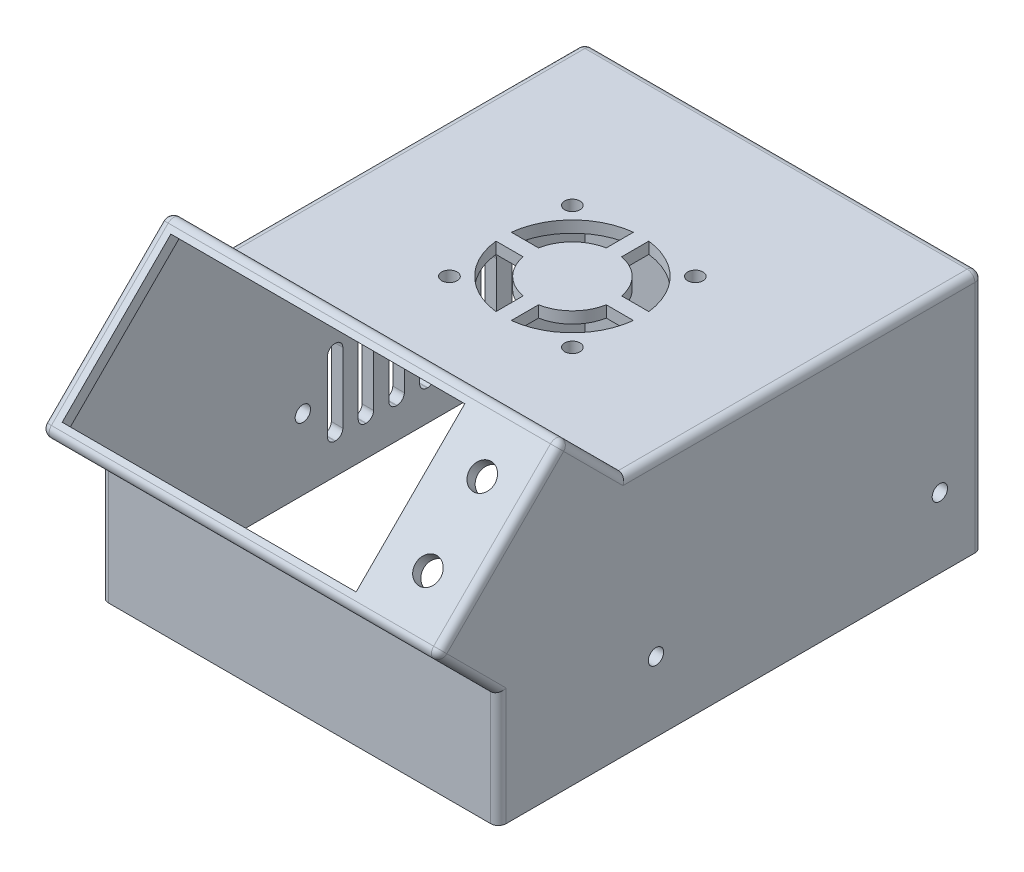
from build123d import *

# Parameters (mm, degrees)
SKETCH1_W           = 103.5
SKETCH1_H           = 126
SKETCH1_W_2         = 97.5
SKETCH1_H_2         = 120
BOSS_EXTRUDE1_DEPTH = 60
SKETCH2_W           = 103.5
SKETCH2_H           = 126
BOSS_EXTRUDE2_DEPTH = 3
CUT_EXTRUDE1_REACH  = 105.5
SKETCH5_W           = 103.5
SKETCH5_H           = 47
SKETCH5_W_2         = 97.5
SKETCH5_H_2         = 41
BOSS_EXTRUDE4_DEPTH = 20
SKETCH6_W           = 97.5
SKETCH6_H           = 41
CUT_EXTRUDE2_DEPTH  = 3
SKETCH7_W           = 103.5
SKETCH7_H           = 47
SKETCH7_R           = 3.25
SKETCH7_W_2         = 76.5
SKETCH7_H_2         = 40
BOSS_EXTRUDE5_DEPTH = 3
CUT_EXTRUDE3_REACH  = 144.263
SKETCH8_R           = 2
SKETCH8_R_2         = 10.5
CUT_EXTRUDE5_REACH  = 65
SKETCH10_R          = 2
SKETCH11_R          = 3
SKETCH11_R_2        = 1
BOSS_EXTRUDE6_DEPTH = 5
CUT_EXTRUDE6_REACH  = 105.5
SKETCH12_R          = 2
SKETCH13_R          = 2
CUT_EXTRUDE7_DEPTH  = 5
FILLET2_R           = 2
FILLET3_R           = 2


with BuildPart() as part:
    # Sketch1 → Boss-Extrude1 (new body)
    with BuildSketch(Plane(origin=(0, 0, 0), x_dir=(1, 0, 0), z_dir=(0, 1, 0))):
        with Locations((48.75, 60)):
            Rectangle(SKETCH1_W, SKETCH1_H)
        with Locations((48.75, 60)):
            Rectangle(SKETCH1_W_2, SKETCH1_H_2, mode=Mode.SUBTRACT)
    extrude(amount=BOSS_EXTRUDE1_DEPTH)

    # Sketch2 → Boss-Extrude2 (add)
    with BuildSketch(Plane(origin=(0, 60, 0), x_dir=(1, 0, 0), z_dir=(0, 1, 0))):
        with Locations((48.75, 60)):
            Rectangle(SKETCH2_W, SKETCH2_H)
    extrude(amount=BOSS_EXTRUDE2_DEPTH)

    # Sketch4 → Cut-Extrude1 (cut, up to next)
    with BuildSketch(Plane(origin=(100.5, 0, 0), x_dir=(0, 0, -1), z_dir=(1, 0, 0)), mode=Mode.PRIVATE) as cut_extrude1_sk1:
        Polygon((-3, 63), (-3, 29.765981284), (30.234018716, 63), align=None)
    cut_extrude1_tool1 = extrude(cut_extrude1_sk1.sketch, amount=-CUT_EXTRUDE1_REACH, mode=Mode.PRIVATE) & part.part
    add(cut_extrude1_tool1.solids().sort_by_distance((100.5, 51.921994, -8.078006))[0], mode=Mode.SUBTRACT)

    # Sketch5 → Boss-Extrude4 (add)
    with BuildSketch(Plane(origin=(0, 16.382990642, 16.382990642), x_dir=(1, 0, 0), z_dir=(0, 0.707106781, 0.707106781))):
        with Locations((48.75, 42.426406871)):
            Rectangle(SKETCH5_W, SKETCH5_H)
        with Locations((48.75, 42.426406871)):
            Rectangle(SKETCH5_W_2, SKETCH5_H_2, mode=Mode.SUBTRACT)
    extrude(amount=BOSS_EXTRUDE4_DEPTH)

    # Sketch6 → Cut-Extrude2 (cut)
    with BuildSketch(Plane(origin=(0, 16.382990642, 16.382990642), x_dir=(1, 0, 0), z_dir=(0, 0.707106781, 0.707106781))):
        with Locations((48.75, 42.426406871)):
            Rectangle(SKETCH6_W, SKETCH6_H)
    extrude(amount=-CUT_EXTRUDE2_DEPTH, mode=Mode.SUBTRACT)

    # Sketch7 → Boss-Extrude5 (add)
    with BuildSketch(Plane(origin=(0, 30.525126266, 30.525126266), x_dir=(1, 0, 0), z_dir=(0, 0.707106781, 0.707106781))):
        with Locations((48.75, 42.426406871)):
            Rectangle(SKETCH7_W, SKETCH7_H)
        with Locations(Location((88.875, 52.426406871, 0), (0, 0, 270))):  # turned: the seam where the file's is
            Circle(SKETCH7_R, mode=Mode.SUBTRACT)
        with Locations(Location((88.875, 32.426406871, 0), (0, 0, 270))):  # turned: the seam where the file's is
            Circle(SKETCH7_R, mode=Mode.SUBTRACT)
        with Locations((39, 42.426406871)):
            Rectangle(SKETCH7_W_2, SKETCH7_H_2, mode=Mode.SUBTRACT)
    extrude(amount=BOSS_EXTRUDE5_DEPTH)

    # Sketch8 → Cut-Extrude3 (cut, up to next)
    with BuildSketch(Plane(origin=(0, 0, -123), x_dir=(-1, 0, 0), z_dir=(0, 0, -1)), mode=Mode.PRIVATE) as cut_extrude3_sk1:
        with Locations((-54.5, 48.5)):
            Circle(SKETCH8_R)
    cut_extrude3_tool1 = extrude(cut_extrude3_sk1.sketch, amount=-CUT_EXTRUDE3_REACH, mode=Mode.PRIVATE) & part.part
    add(cut_extrude3_tool1.solids().sort_by_distance((54.5, 48.5, -123))[0], mode=Mode.SUBTRACT)
    # Sketch8 → Cut-Extrude3 (cut, up to next)
    with BuildSketch(Plane(origin=(0, 0, -123), x_dir=(-1, 0, 0), z_dir=(0, 0, -1)), mode=Mode.PRIVATE) as cut_extrude3_sk2:
        with Locations((-14.5, 48.5)):
            Circle(SKETCH8_R)
    cut_extrude3_tool2 = extrude(cut_extrude3_sk2.sketch, amount=-CUT_EXTRUDE3_REACH, mode=Mode.PRIVATE) & part.part
    add(cut_extrude3_tool2.solids().sort_by_distance((14.5, 48.5, -123))[0], mode=Mode.SUBTRACT)
    # Sketch8 → Cut-Extrude3 (cut, up to next)
    with BuildSketch(Plane(origin=(0, 0, -123), x_dir=(-1, 0, 0), z_dir=(0, 0, -1)), mode=Mode.PRIVATE) as cut_extrude3_sk3:
        with Locations((-74.5, 48.5)):
            Circle(SKETCH8_R_2)
    cut_extrude3_tool3 = extrude(cut_extrude3_sk3.sketch, amount=-CUT_EXTRUDE3_REACH, mode=Mode.PRIVATE) & part.part
    add(cut_extrude3_tool3.solids().sort_by_distance((74.5, 48.5, -123))[0], mode=Mode.SUBTRACT)
    # Sketch8 → Cut-Extrude3 (cut, up to next)
    with BuildSketch(Plane(origin=(0, 0, -123), x_dir=(-1, 0, 0), z_dir=(0, 0, -1)), mode=Mode.PRIVATE) as cut_extrude3_sk4:
        with Locations((-44, 28.7)):
            Circle(SKETCH8_R)
    cut_extrude3_tool4 = extrude(cut_extrude3_sk4.sketch, amount=-CUT_EXTRUDE3_REACH, mode=Mode.PRIVATE) & part.part
    add(cut_extrude3_tool4.solids().sort_by_distance((44, 28.7, -123))[0], mode=Mode.SUBTRACT)
    # Sketch8 → Cut-Extrude3 (cut, up to next)
    with BuildSketch(Plane(origin=(0, 0, -123), x_dir=(-1, 0, 0), z_dir=(0, 0, -1)), mode=Mode.PRIVATE) as cut_extrude3_sk5:
        with BuildLine():
            Line((-46.25, 58), (-22.75, 58))
            ThreePointArc((-22.75, 58), (-21.335786438, 57.414213562), (-20.75, 56))
            Line((-20.75, 56), (-20.75, 41))
            ThreePointArc((-20.75, 41), (-21.335786438, 39.585786438), (-22.75, 39))
            Line((-22.75, 39), (-46.25, 39))
            ThreePointArc((-46.25, 39), (-47.664213562, 39.585786438), (-48.25, 41))
            Line((-48.25, 41), (-48.25, 56))
            ThreePointArc((-48.25, 56), (-47.664213562, 57.414213562), (-46.25, 58))
        make_face()
    cut_extrude3_tool5 = extrude(cut_extrude3_sk5.sketch, amount=-CUT_EXTRUDE3_REACH, mode=Mode.PRIVATE) & part.part
    add(cut_extrude3_tool5.solids().sort_by_distance((34.5, 48.5, -123))[0], mode=Mode.SUBTRACT)

    # Sketch10 → Cut-Extrude5 (cut, up to next)
    with BuildSketch(Plane(origin=(0, 63, 0), x_dir=(1, 0, 0), z_dir=(0, 1, 0)), mode=Mode.PRIVATE) as cut_extrude5_sk1:
        with Locations(Location((32.75, 84, 0), (0, 0, 270))):  # turned: the seam where the file's is
            Circle(SKETCH10_R)
    cut_extrude5_tool1 = extrude(cut_extrude5_sk1.sketch, amount=-CUT_EXTRUDE5_REACH, mode=Mode.PRIVATE) & part.part
    add(cut_extrude5_tool1.solids().sort_by_distance((32.75, 63, -84))[0], mode=Mode.SUBTRACT)
    # Sketch10 → Cut-Extrude5 (cut, up to next)
    with BuildSketch(Plane(origin=(0, 63, 0), x_dir=(1, 0, 0), z_dir=(0, 1, 0)), mode=Mode.PRIVATE) as cut_extrude5_sk2:
        with Locations(Location((64.75, 84, 0), (0, 0, 270))):  # turned: the seam where the file's is
            Circle(SKETCH10_R)
    cut_extrude5_tool2 = extrude(cut_extrude5_sk2.sketch, amount=-CUT_EXTRUDE5_REACH, mode=Mode.PRIVATE) & part.part
    add(cut_extrude5_tool2.solids().sort_by_distance((64.75, 63, -84))[0], mode=Mode.SUBTRACT)
    # Sketch10 → Cut-Extrude5 (cut, up to next)
    with BuildSketch(Plane(origin=(0, 63, 0), x_dir=(1, 0, 0), z_dir=(0, 1, 0)), mode=Mode.PRIVATE) as cut_extrude5_sk3:
        with Locations(Location((32.75, 52, 0), (0, 0, 270))):  # turned: the seam where the file's is
            Circle(SKETCH10_R)
    cut_extrude5_tool3 = extrude(cut_extrude5_sk3.sketch, amount=-CUT_EXTRUDE5_REACH, mode=Mode.PRIVATE) & part.part
    add(cut_extrude5_tool3.solids().sort_by_distance((32.75, 63, -52))[0], mode=Mode.SUBTRACT)
    # Sketch10 → Cut-Extrude5 (cut, up to next)
    with BuildSketch(Plane(origin=(0, 63, 0), x_dir=(1, 0, 0), z_dir=(0, 1, 0)), mode=Mode.PRIVATE) as cut_extrude5_sk4:
        with Locations(Location((64.75, 52, 0), (0, 0, 270))):  # turned: the seam where the file's is
            Circle(SKETCH10_R)
    cut_extrude5_tool4 = extrude(cut_extrude5_sk4.sketch, amount=-CUT_EXTRUDE5_REACH, mode=Mode.PRIVATE) & part.part
    add(cut_extrude5_tool4.solids().sort_by_distance((64.75, 63, -52))[0], mode=Mode.SUBTRACT)
    # Sketch10 → Cut-Extrude5 (cut, up to next)
    with BuildSketch(Plane(origin=(0, 63, 0), x_dir=(1, 0, 0), z_dir=(0, 1, 0)), mode=Mode.PRIVATE) as cut_extrude5_sk5:
        with BuildLine():
            Line((46.75, 85.88854382), (46.75, 78.816653826))
            ThreePointArc((46.75, 78.816653826), (40.971825407, 75.778174593), (37.933346174, 70))
            Line((37.933346174, 70), (30.86145618, 70))
            ThreePointArc((30.86145618, 70), (36.022077939, 80.727922061), (46.75, 85.88854382))
        make_face()
    cut_extrude5_tool5 = extrude(cut_extrude5_sk5.sketch, amount=-CUT_EXTRUDE5_REACH, mode=Mode.PRIVATE) & part.part
    add(cut_extrude5_tool5.solids().sort_by_distance((38.979512, 63, -77.770488))[0], mode=Mode.SUBTRACT)
    # Sketch10 → Cut-Extrude5 (cut, up to next)
    with BuildSketch(Plane(origin=(0, 63, 0), x_dir=(1, 0, 0), z_dir=(0, 1, 0)), mode=Mode.PRIVATE) as cut_extrude5_sk6:
        with BuildLine():
            Line((50.75, 85.88854382), (50.75, 78.816653826))
            ThreePointArc((50.75, 78.816653826), (56.528174593, 75.778174593), (59.566653826, 70))
            Line((59.566653826, 70), (66.63854382, 70))
            ThreePointArc((66.63854382, 70), (61.477922061, 80.727922061), (50.75, 85.88854382))
        make_face()
    cut_extrude5_tool6 = extrude(cut_extrude5_sk6.sketch, amount=-CUT_EXTRUDE5_REACH, mode=Mode.PRIVATE) & part.part
    add(cut_extrude5_tool6.solids().sort_by_distance((58.520488, 63, -77.770488))[0], mode=Mode.SUBTRACT)
    # Sketch10 → Cut-Extrude5 (cut, up to next)
    with BuildSketch(Plane(origin=(0, 63, 0), x_dir=(1, 0, 0), z_dir=(0, 1, 0)), mode=Mode.PRIVATE) as cut_extrude5_sk7:
        with BuildLine():
            Line((30.86145618, 66), (37.933346174, 66))
            ThreePointArc((37.933346174, 66), (40.971825407, 60.221825407), (46.75, 57.183346174))
            Line((46.75, 57.183346174), (46.75, 50.11145618))
            ThreePointArc((46.75, 50.11145618), (36.022077939, 55.272077939), (30.86145618, 66))
        make_face()
    cut_extrude5_tool7 = extrude(cut_extrude5_sk7.sketch, amount=-CUT_EXTRUDE5_REACH, mode=Mode.PRIVATE) & part.part
    add(cut_extrude5_tool7.solids().sort_by_distance((38.979512, 63, -58.229512))[0], mode=Mode.SUBTRACT)
    # Sketch10 → Cut-Extrude5 (cut, up to next)
    with BuildSketch(Plane(origin=(0, 63, 0), x_dir=(1, 0, 0), z_dir=(0, 1, 0)), mode=Mode.PRIVATE) as cut_extrude5_sk8:
        with BuildLine():
            Line((59.566653826, 66), (66.63854382, 66))
            ThreePointArc((66.63854382, 66), (61.477922061, 55.272077939), (50.75, 50.11145618))
            Line((50.75, 50.11145618), (50.75, 57.183346174))
            ThreePointArc((50.75, 57.183346174), (56.528174593, 60.221825407), (59.566653826, 66))
        make_face()
    cut_extrude5_tool8 = extrude(cut_extrude5_sk8.sketch, amount=-CUT_EXTRUDE5_REACH, mode=Mode.PRIVATE) & part.part
    add(cut_extrude5_tool8.solids().sort_by_distance((58.520488, 63, -58.229512))[0], mode=Mode.SUBTRACT)

    # Sketch11 → Boss-Extrude6 (add)
    with BuildSketch(Plane.XZ.offset(-60)):
        with Locations(Location((81.1, -47.091378029, 0), (0, 0, 90))):  # turned: the seam where the file's is
            Circle(SKETCH11_R)
        with Locations(Location((81.1, -47.091378029, 0), (0, 0, 270))):  # turned: the seam where the file's is
            Circle(SKETCH11_R_2, mode=Mode.SUBTRACT)
        with Locations(Location((92.8, -79.991378029, 0), (0, 0, 90))):  # turned: the seam where the file's is
            Circle(SKETCH11_R)
        with Locations(Location((92.8, -79.991378029, 0), (0, 0, 270))):  # turned: the seam where the file's is
            Circle(SKETCH11_R_2, mode=Mode.SUBTRACT)
    extrude(amount=BOSS_EXTRUDE6_DEPTH)

    # Sketch12 → Cut-Extrude6 (cut, up to next)
    with BuildSketch(Plane(origin=(100.5, 0, 0), x_dir=(0, 0, -1), z_dir=(1, 0, 0)), mode=Mode.PRIVATE) as cut_extrude6_sk1:
        with Locations((111.9, 18.2)):
            Circle(SKETCH12_R)
    cut_extrude6_tool1 = extrude(cut_extrude6_sk1.sketch, amount=-CUT_EXTRUDE6_REACH, mode=Mode.PRIVATE) & part.part
    add(cut_extrude6_tool1.solids().sort_by_distance((100.5, 18.2, -111.9))[0], mode=Mode.SUBTRACT)
    # Sketch12 → Cut-Extrude6 (cut, up to next)
    with BuildSketch(Plane(origin=(100.5, 0, 0), x_dir=(0, 0, -1), z_dir=(1, 0, 0)), mode=Mode.PRIVATE) as cut_extrude6_sk2:
        with Locations((38, 18.2)):
            Circle(SKETCH12_R)
    cut_extrude6_tool2 = extrude(cut_extrude6_sk2.sketch, amount=-CUT_EXTRUDE6_REACH, mode=Mode.PRIVATE) & part.part
    add(cut_extrude6_tool2.solids().sort_by_distance((100.5, 18.2, -38))[0], mode=Mode.SUBTRACT)

    # Sketch13 → Cut-Extrude7 (cut)
    with BuildSketch(Plane.ZY.offset(3)):
        with Locations((-112.8, 18.4)):
            Circle(SKETCH13_R)
        with Locations((-46.6, 18.4)):
            Circle(SKETCH13_R)
        with BuildLine():
            Line((-97.005880711, 28.1), (-97.005880711, 9.9))
            ThreePointArc((-97.005880711, 9.9), (-96.449383595, 8.556497116), (-95.105880711, 8))
            Line((-95.105880711, 8), (-94.905880711, 8))
            ThreePointArc((-94.905880711, 8), (-93.562377827, 8.556497116), (-93.005880711, 9.9))
            Line((-93.005880711, 9.9), (-93.005880711, 28.1))
            ThreePointArc((-93.005880711, 28.1), (-93.562377827, 29.443502884), (-94.905880711, 30))
            Line((-94.905880711, 30), (-95.105880711, 30))
            ThreePointArc((-95.105880711, 30), (-96.449383595, 29.443502884), (-97.005880711, 28.1))
        make_face()
        with BuildLine():
            Line((-103.105880711, 30), (-102.905880711, 30))
            ThreePointArc((-102.905880711, 30), (-101.562377827, 29.443502884), (-101.005880711, 28.1))
            Line((-101.005880711, 28.1), (-101.005880711, 9.9))
            ThreePointArc((-101.005880711, 9.9), (-101.562377827, 8.556497116), (-102.905880711, 8))
            Line((-102.905880711, 8), (-103.105880711, 8))
            ThreePointArc((-103.105880711, 8), (-104.449383595, 8.556497116), (-105.005880711, 9.9))
            Line((-105.005880711, 9.9), (-105.005880711, 28.1))
            ThreePointArc((-105.005880711, 28.1), (-104.449383595, 29.443502884), (-103.105880711, 30))
        make_face()
        with BuildLine():
            Line((-89.005880711, 28.1), (-89.005880711, 9.9))
            ThreePointArc((-89.005880711, 9.9), (-88.449383595, 8.556497116), (-87.105880711, 8))
            Line((-87.105880711, 8), (-86.905880711, 8))
            ThreePointArc((-86.905880711, 8), (-85.562377827, 8.556497116), (-85.005880711, 9.9))
            Line((-85.005880711, 9.9), (-85.005880711, 28.1))
            ThreePointArc((-85.005880711, 28.1), (-85.562377827, 29.443502884), (-86.905880711, 30))
            Line((-86.905880711, 30), (-87.105880711, 30))
            ThreePointArc((-87.105880711, 30), (-88.449383595, 29.443502884), (-89.005880711, 28.1))
        make_face()
        with BuildLine():
            Line((-81.005880711, 28.1), (-81.005880711, 9.9))
            ThreePointArc((-81.005880711, 9.9), (-80.449383595, 8.556497116), (-79.105880711, 8))
            Line((-79.105880711, 8), (-78.905880711, 8))
            ThreePointArc((-78.905880711, 8), (-77.562377827, 8.556497116), (-77.005880711, 9.9))
            Line((-77.005880711, 9.9), (-77.005880711, 28.1))
            ThreePointArc((-77.005880711, 28.1), (-77.562377827, 29.443502884), (-78.905880711, 30))
            Line((-78.905880711, 30), (-79.105880711, 30))
            ThreePointArc((-79.105880711, 30), (-80.449383595, 29.443502884), (-81.005880711, 28.1))
        make_face()
        with BuildLine():
            Line((-73.005880711, 28.1), (-73.005880711, 9.9))
            ThreePointArc((-73.005880711, 9.9), (-72.449383595, 8.556497116), (-71.105880711, 8))
            Line((-71.105880711, 8), (-70.905880711, 8))
            ThreePointArc((-70.905880711, 8), (-69.562377827, 8.556497116), (-69.005880711, 9.9))
            Line((-69.005880711, 9.9), (-69.005880711, 28.1))
            ThreePointArc((-69.005880711, 28.1), (-69.562377827, 29.443502884), (-70.905880711, 30))
            Line((-70.905880711, 30), (-71.105880711, 30))
            ThreePointArc((-71.105880711, 30), (-72.449383595, 29.443502884), (-73.005880711, 28.1))
        make_face()
        with BuildLine():
            Line((-65.005880711, 28.1), (-65.005880711, 9.9))
            ThreePointArc((-65.005880711, 9.9), (-64.449383595, 8.556497116), (-63.105880711, 8))
            Line((-63.105880711, 8), (-62.905880711, 8))
            ThreePointArc((-62.905880711, 8), (-61.562377827, 8.556497116), (-61.005880711, 9.9))
            Line((-61.005880711, 9.9), (-61.005880711, 28.1))
            ThreePointArc((-61.005880711, 28.1), (-61.562377827, 29.443502884), (-62.905880711, 30))
            Line((-62.905880711, 30), (-63.105880711, 30))
            ThreePointArc((-63.105880711, 30), (-64.449383595, 29.443502884), (-65.005880711, 28.1))
        make_face()
        with BuildLine():
            Line((-57.005880711, 28.1), (-57.005880711, 9.9))
            ThreePointArc((-57.005880711, 9.9), (-56.449383595, 8.556497116), (-55.105880711, 8))
            Line((-55.105880711, 8), (-54.905880711, 8))
            ThreePointArc((-54.905880711, 8), (-53.562377827, 8.556497116), (-53.005880711, 9.9))
            Line((-53.005880711, 9.9), (-53.005880711, 28.1))
            ThreePointArc((-53.005880711, 28.1), (-53.562377827, 29.443502884), (-54.905880711, 30))
            Line((-54.905880711, 30), (-55.105880711, 30))
            ThreePointArc((-55.105880711, 30), (-56.449383595, 29.443502884), (-57.005880711, 28.1))
        make_face()
    extrude(amount=-CUT_EXTRUDE7_DEPTH, mode=Mode.SUBTRACT)

    # Fillet2
    fillet2_edges = [part.edges().sort_by_distance(p)[0] for p in [
        (-3, 62.646446609, 2.646446609),
        (48.75, 46.029437252, 19.263455967),
        (100.5, 62.646446609, 2.646446609),
        (48.75, 79.263455967, -13.970562748),
        (-3, 71.131727984, -22.102290732),
        (-3, 37.897709268, 11.131727984),
        (100.5, 37.897709268, 11.131727984),
        (100.5, 71.131727984, -22.102290732),
    ]]
    fillet(fillet2_edges, radius=FILLET2_R)

    # Fillet3
    fillet3_edges = [part.edges().sort_by_distance(p)[0] for p in [
        (100.5, 31.5, -123),
        (100.5, 63, -76.617009358),
        (100.5, 14.882990642, 3),
        (-3, 14.882990642, 3),
        (-3, 31.5, -123),
        (48.75, 63, -123),
        (-3, 63, -76.617009358),
    ]]
    fillet(fillet3_edges, radius=FILLET3_R)


solid = part.part
